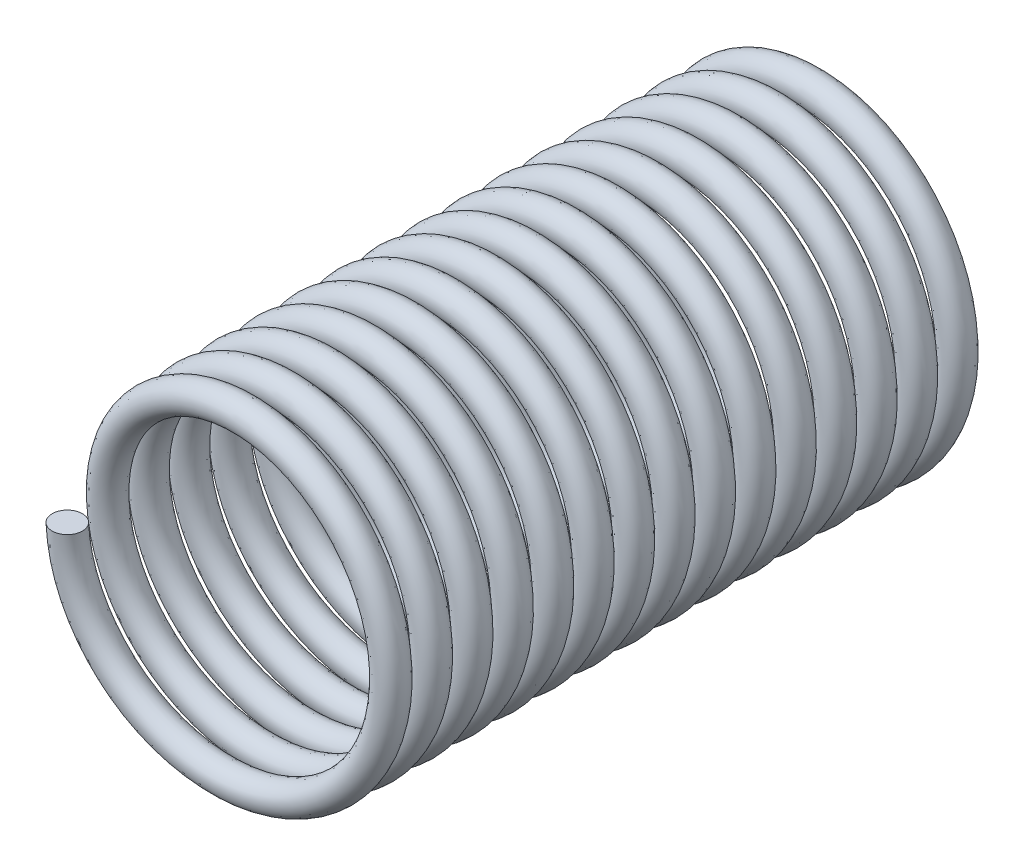
from build123d import *

# Parameters (mm, degrees)
SWEEP1_PITCH       = 1.333333333
SWEEP1_HEIGHT      = 20
SWEEP1_RADIUS      = 5
SWEEP1_START_ANGLE = -180
SKETCH2_R          = 0.497145534


with BuildPart() as part:
    # Sweep1: sweep along a helix
    with BuildLine() as sweep1_path:
        add(Helix(SWEEP1_PITCH, SWEEP1_HEIGHT, SWEEP1_RADIUS, center=(0, 0, 0), direction=(0, 0, 1), lefthand=True, mode=Mode.PRIVATE).rotate(Axis((0, 0, 0), (0, 0, 1)), SWEEP1_START_ANGLE))
    # Sketch2 → Sweep1 (sweep)
    with BuildSketch(Plane(origin=(0, 0, 0), x_dir=(1, 0, 0), z_dir=(0, 1, 0))):
        with Locations((-5, -20)):
            Circle(SKETCH2_R)
    sweep(path=sweep1_path.line, is_frenet=True)


solid = part.part
